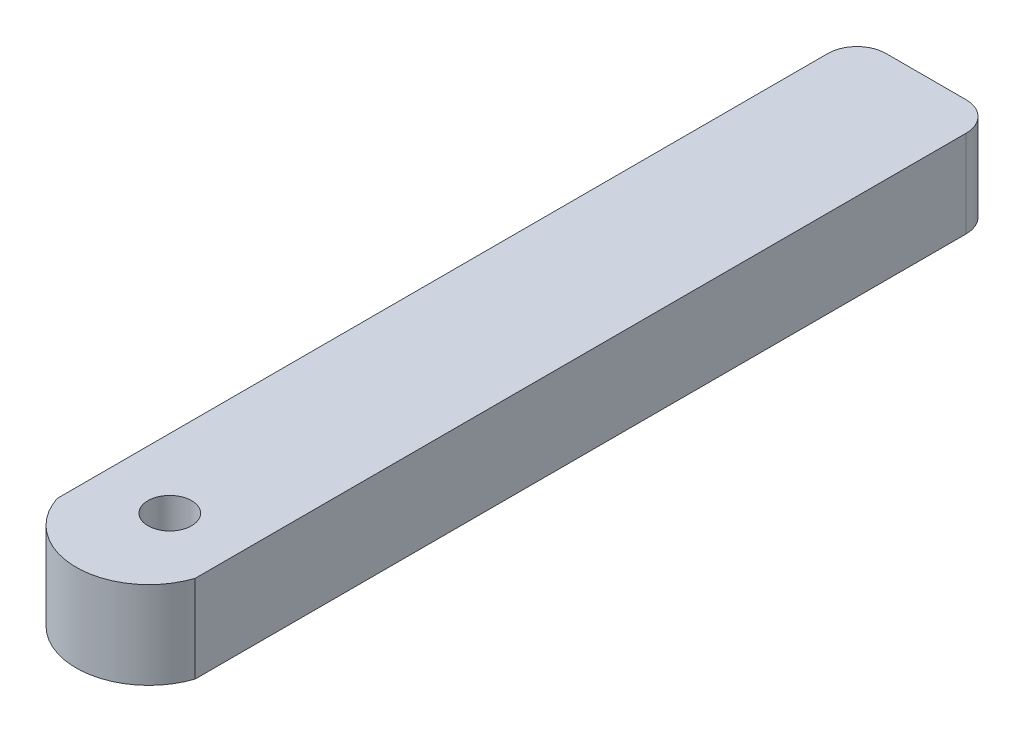
from build123d import *

# Parameters (mm, degrees)
ESQUISSE1_R        = 1.5
BOSS_EXTRU_1_DEPTH = 6
CONG_1_R           = 2


with BuildPart() as part:
    # Esquisse1 → Boss.-Extru.1 (new body)
    with BuildSketch(Plane(origin=(0, 0, 0), x_dir=(1, 0, 0), z_dir=(0, 1, 0))):
        with BuildLine():
            Line((4.75, 40), (-4.75, 40))
            Line((-4.75, 40), (-4.75, -15))
            ThreePointArc((-4.75, -15), (0, -18.4387505), (4.75, -15))
            Line((4.75, -15), (4.75, 40))
        make_face()
        with Locations((0, -12)):
            Circle(ESQUISSE1_R, mode=Mode.SUBTRACT)
    extrude(amount=BOSS_EXTRU_1_DEPTH)

    # Congé1
    cong_1_edges = [part.edges().sort_by_distance(p)[0] for p in [
        (-4.75, 3, -40),
        (4.75, 3, -40),
    ]]
    fillet(cong_1_edges, radius=CONG_1_R)


solid = part.part
